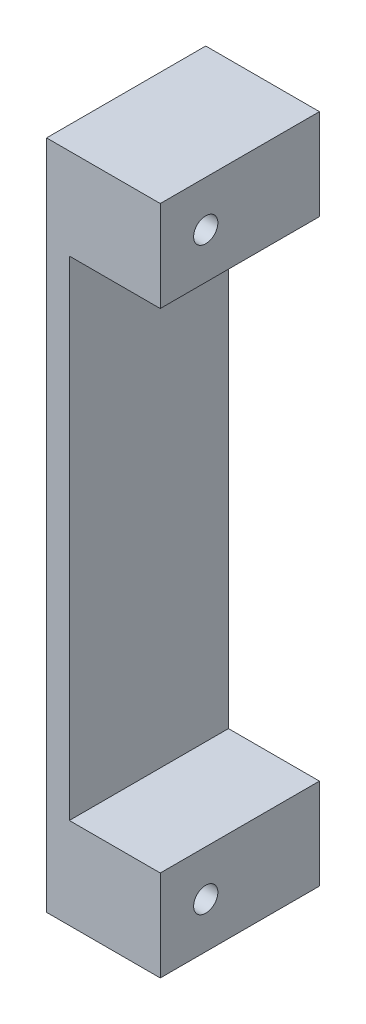
from build123d import *

# Parameters (mm, degrees)
SKETCH1_W                 = 17.78
SKETCH1_H                 = 74.93
BOSS_EXTRUDE1_DEPTH       = 12.7
CUT_EXTRUDE1_DEPTH        = 10.16
TAP_DRILL_FOR_6_32_TAP1_D = 2.7051
SKETCH5_R                 = 2.39395
CUT_EXTRUDE2_DEPTH        = 11.1125


with BuildPart() as part:
    # Sketch1 → Boss-Extrude1 (new body)
    with BuildSketch(Plane(origin=(0, 0, 0), x_dir=(0, 0, -1), z_dir=(1, 0, 0))):
        with Locations((8.89, 37.465)):
            Rectangle(SKETCH1_W, SKETCH1_H)
    extrude(amount=BOSS_EXTRUDE1_DEPTH)

    # Sketch2 → Cut-Extrude1 (cut)
    with BuildSketch(Plane(origin=(12.7, 0, 0), x_dir=(0, 0, -1), z_dir=(1, 0, 0))):
        Polygon((0, 64.77), (10.16, 64.77), (13.97, 64.77), (24.13, 64.77), (24.13, 10.16), (13.97, 10.16), (10.16, 10.16), (0, 10.16), align=None)
    extrude(amount=-CUT_EXTRUDE1_DEPTH, mode=Mode.SUBTRACT)

    # Tap Drill for #6-32 Tap1 (through all)
    with Locations(Plane(origin=(12.7, 0, 0), x_dir=(0, 0, -1), z_dir=(1, 0, 0))):
        with Locations((5.08, 69.85), (5.08, 5.08)):
            Hole(TAP_DRILL_FOR_6_32_TAP1_D / 2)

    # Sketch5 → Cut-Extrude2 (cut)
    with BuildSketch(Plane(origin=(0, 0, -17.78), x_dir=(-1, 0, 0), z_dir=(0, 0, -1))):
        with Locations((-6.35, 69.85)):
            Circle(SKETCH5_R)
        with BuildLine():
            Line((-8.74395, 4.953), (-8.74395, 5.207))
            ThreePointArc((-8.74395, 5.207), (-6.35, 7.60095), (-3.95605, 5.207))
            Line((-3.95605, 5.207), (-3.95605, 4.953))
            ThreePointArc((-3.95605, 4.953), (-6.35, 2.55905), (-8.74395, 4.953))
        make_face()
    extrude(amount=-CUT_EXTRUDE2_DEPTH, mode=Mode.SUBTRACT)


solid = part.part
